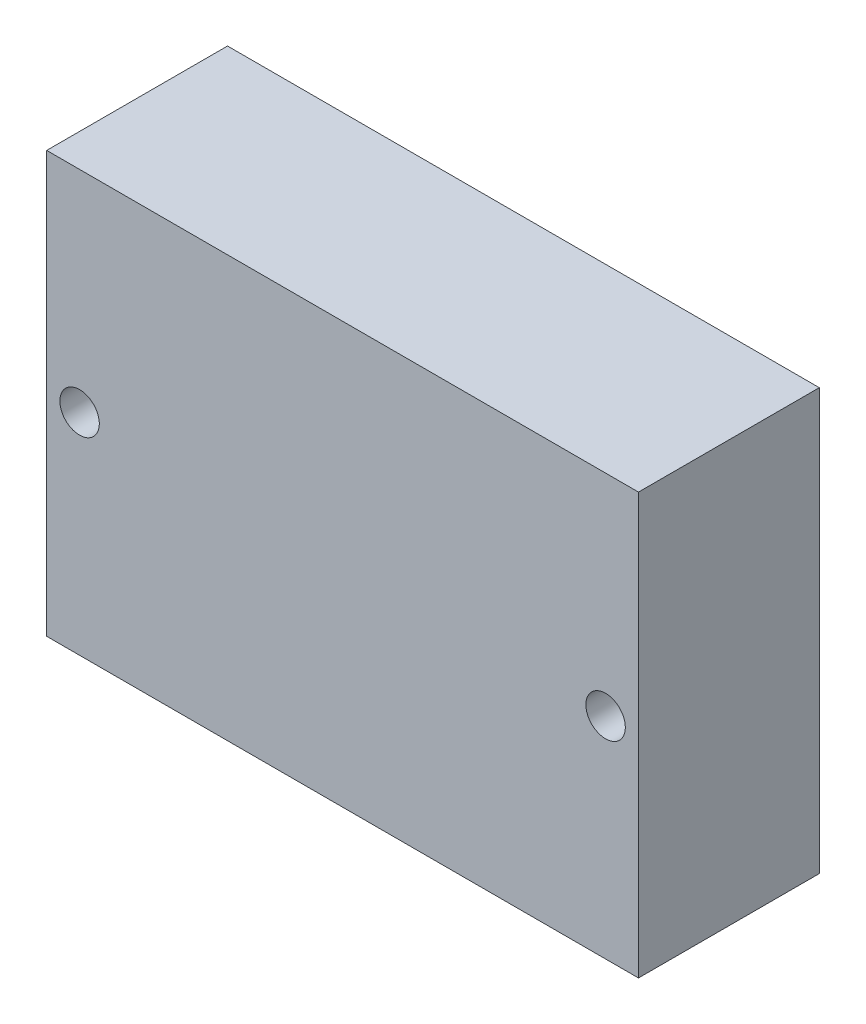
from build123d import *

# Parameters (mm, degrees)
SKETCH1_W           = 45
SKETCH1_H           = 32
SKETCH1_R           = 1.5
BOSS_EXTRUDE1_DEPTH = 13.75


with BuildPart() as part:
    # Sketch1 → Boss-Extrude1 (new body)
    with BuildSketch(Plane.XY):
        with Locations((34.65, -24.64)):
            Rectangle(SKETCH1_W, SKETCH1_H)
        with Locations((54.65, -24.64)):
            Circle(SKETCH1_R, mode=Mode.SUBTRACT)
        with Locations((14.65, -24.64)):
            Circle(SKETCH1_R, mode=Mode.SUBTRACT)
    extrude(amount=BOSS_EXTRUDE1_DEPTH)


solid = part.part
